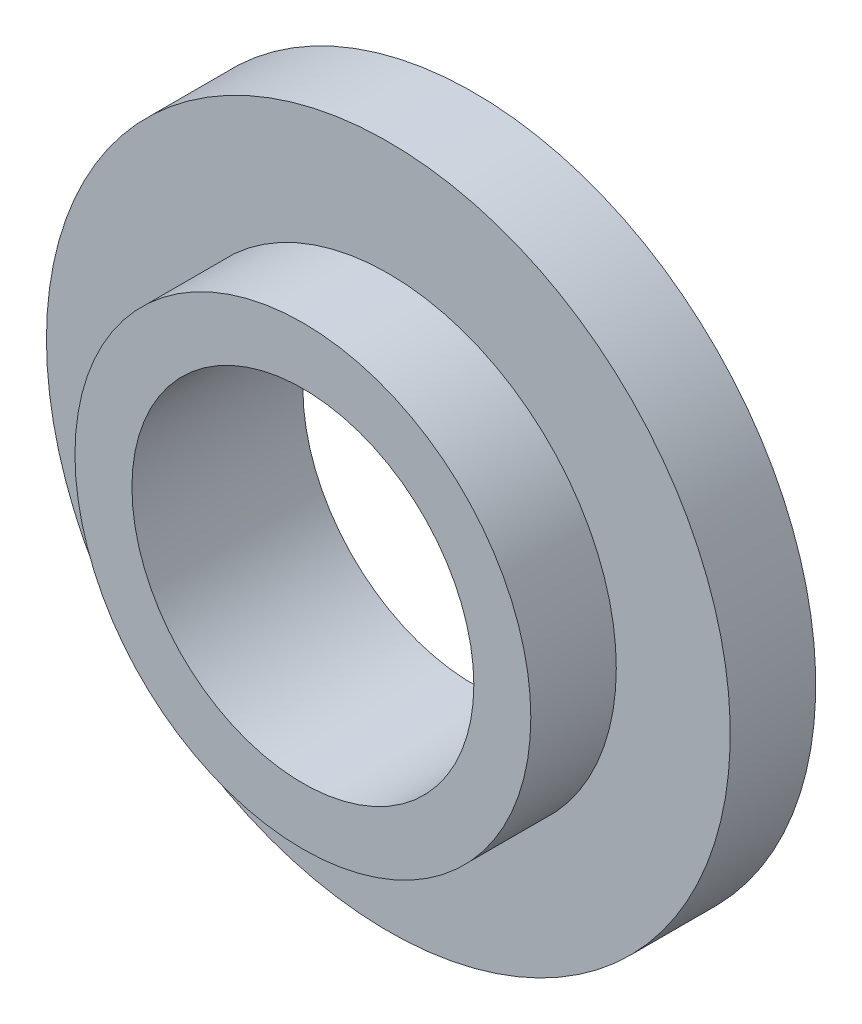
from build123d import *

# Parameters (mm, degrees)
SKETCH1_R           = 20
SKETCH1_R_2         = 15
BOSS_EXTRUDE1_DEPTH = 15
SKETCH2_R           = 30
SKETCH2_R_2         = 20
BOSS_EXTRUDE2_DEPTH = 7.5


with BuildPart() as part:
    # Sketch1 → Boss-Extrude1 (new body)
    with BuildSketch(Plane.XY):
        Circle(SKETCH1_R)
        Circle(SKETCH1_R_2, mode=Mode.SUBTRACT)
    extrude(amount=BOSS_EXTRUDE1_DEPTH)

    # Sketch2 → Boss-Extrude2 (add)
    with BuildSketch(Plane(origin=(0, 0, 0), x_dir=(-1, 0, 0), z_dir=(0, 0, -1))):
        Circle(SKETCH2_R)
        Circle(SKETCH2_R_2, mode=Mode.SUBTRACT)
    extrude(amount=-BOSS_EXTRUDE2_DEPTH)


solid = part.part
